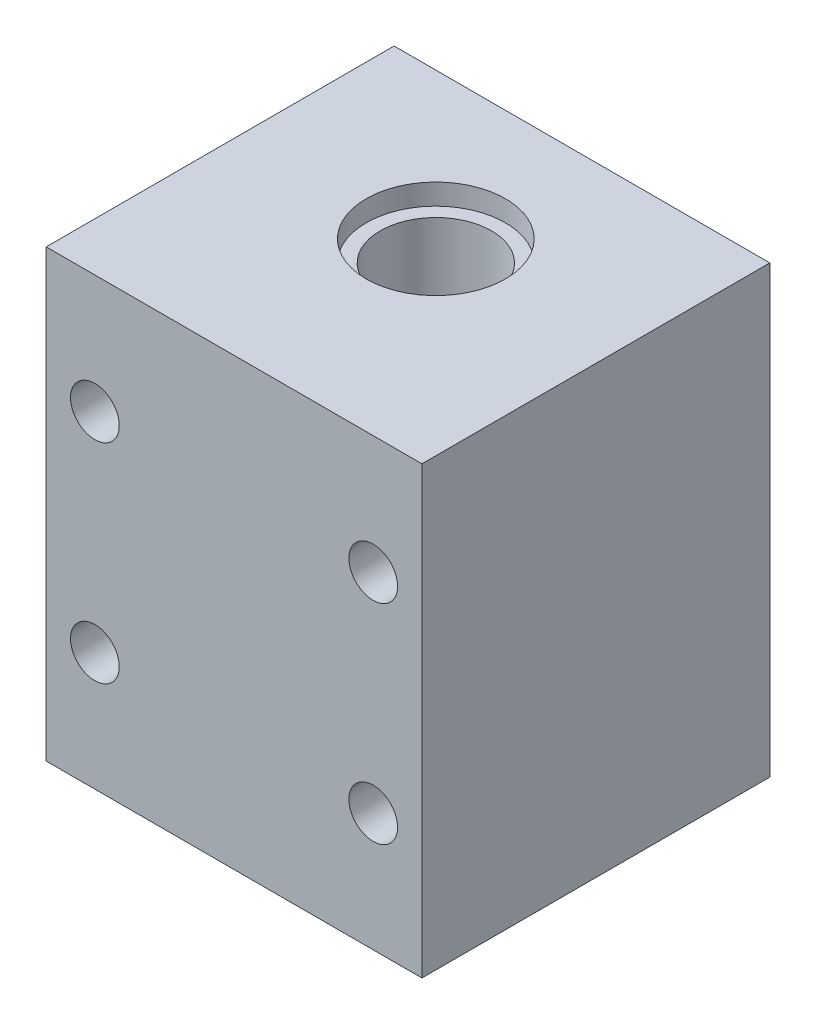
from build123d import *

# Parameters (mm, degrees)
SCHIZZO1_W                   = 27
SCHIZZO1_H                   = 32
ESTRUSIONE_ESTRUSIONE1_DEPTH = 31
SCHIZZO2_R                   = 1.75
TAGLIO_ESTRUSIONE1_DEPTH     = 32
SCHIZZO8_OUTSIDE_W           = 39.42
SCHIZZO8_OUTSIDE_H           = 43.42
SCHIZZO8_OUTSIDE_W_2         = 27
SCHIZZO8_OUTSIDE_H_2         = 25
TAGLIO_ESTRUSIONE7_DEPTH     = 33
SCHIZZO10_R                  = 5
TAGLIO_ESTRUSIONE8_DEPTH     = 1.5
SCHIZZO11_R                  = 4
TAGLIO_ESTRUSIONE9_DEPTH     = 33
SCHIZZO12_R                  = 5
TAGLIO_ESTRUSIONE10_DEPTH    = 1.5


with BuildPart() as part:
    # Schizzo1 → Estrusione-Estrusione1 (new body)
    with BuildSketch(Plane.XY):
        Rectangle(SCHIZZO1_W, SCHIZZO1_H)
    extrude(amount=ESTRUSIONE_ESTRUSIONE1_DEPTH)

    # Schizzo2 → Taglio-Estrusione1 (cut, through all)
    with BuildSketch(Plane(origin=(0, 0, 0), x_dir=(-1, 0, 0), z_dir=(0, 0, -1))):
        with Locations((-10, 7.5)):
            Circle(SCHIZZO2_R)
        with Locations((10, 7.5)):
            Circle(SCHIZZO2_R)
        with Locations((10, -7.5)):
            Circle(SCHIZZO2_R)
        with Locations((-10, -7.5)):
            Circle(SCHIZZO2_R)
    extrude(amount=-TAGLIO_ESTRUSIONE1_DEPTH, mode=Mode.SUBTRACT)

    # Schizzo8 outside → Taglio-Estrusione7 (cut, through all)
    with BuildSketch(Plane(origin=(0, 16, 0), x_dir=(1, 0, 0), z_dir=(0, 1, 0))):
        with Locations((0, -15.5)):
            Rectangle(SCHIZZO8_OUTSIDE_W, SCHIZZO8_OUTSIDE_H)
        with Locations((0, -18.5)):
            Rectangle(SCHIZZO8_OUTSIDE_W_2, SCHIZZO8_OUTSIDE_H_2, mode=Mode.SUBTRACT)
    extrude(amount=-TAGLIO_ESTRUSIONE7_DEPTH, mode=Mode.SUBTRACT)

    # Schizzo10 → Taglio-Estrusione8 (cut)
    with BuildSketch(Plane(origin=(0, 16, 0), x_dir=(1, 0, 0), z_dir=(0, 1, 0))):
        with Locations((0, -16.5)):
            Circle(SCHIZZO10_R)
    extrude(amount=-TAGLIO_ESTRUSIONE8_DEPTH, mode=Mode.SUBTRACT)

    # Schizzo11 → Taglio-Estrusione9 (cut, through all)
    with BuildSketch(Plane(origin=(0, 16, 0), x_dir=(1, 0, 0), z_dir=(0, 1, 0))):
        with Locations((0, -16.5)):
            Circle(SCHIZZO11_R)
    extrude(amount=-TAGLIO_ESTRUSIONE9_DEPTH, mode=Mode.SUBTRACT)

    # Schizzo12 → Taglio-Estrusione10 (cut)
    with BuildSketch(Plane.XZ.offset(16)):
        with Locations((0, 16.5)):
            Circle(SCHIZZO12_R)
    extrude(amount=-TAGLIO_ESTRUSIONE10_DEPTH, mode=Mode.SUBTRACT)


solid = part.part
